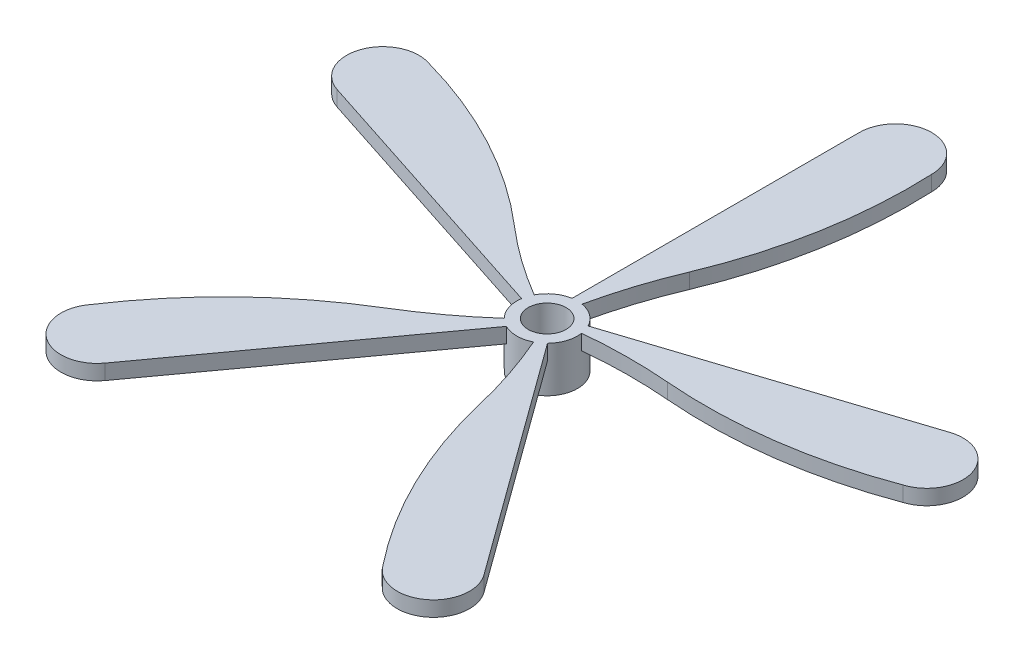
from build123d import *

# Parameters (mm, degrees)
SKETCH1_R           = 4
SKETCH1_R_2         = 2.5
BOSS_EXTRUDE1_DEPTH = 6
BOSS_EXTRUDE2_START = -2
BOSS_EXTRUDE2_DEPTH = 2
CIRPATTERN1_COUNT   = 5


with BuildPart() as part:
    # Sketch1 → Boss-Extrude1 (new body)
    with BuildSketch(Plane(origin=(0, 0, 0), x_dir=(1, 0, 0), z_dir=(0, 1, 0))):
        Circle(SKETCH1_R)
        Circle(SKETCH1_R_2, mode=Mode.SUBTRACT)
    extrude(amount=BOSS_EXTRUDE1_DEPTH)

    # Sketch2 → Boss-Extrude2 (add)
    with BuildSketch(Plane(origin=(0, 6, 0), x_dir=(1, 0, 0), z_dir=(0, 1, 0)).offset(BOSS_EXTRUDE2_START)):
        with BuildLine():
            Line((-0.659397634, 3.945274992), (-0.659397634, 41.803919823))
            ThreePointArc((-0.659397634, 41.803919823), (4.137285492, 46.574729802), (8.882082768, 41.752313842))
            ThreePointArc((8.882082768, 41.752313842), (7.966424676, 27.945777977), (4.058060811, 14.672362658))
            ThreePointArc((4.058060811, 14.672362658), (2.118281369, 9.384999918), (0.659397634, 3.945274992))
            ThreePointArc((0.659397634, 3.945274992), (0, 4), (-0.659397634, 3.945274992))
        make_face()
    boss_extrude2 = extrude(amount=BOSS_EXTRUDE2_DEPTH)

    # CirPattern1: Boss-Extrude2 ×5 about axis
    cirpattern1_axis = Axis((0, -0.3, 0), (0, 1, 0))
    for i in range(1, CIRPATTERN1_COUNT):
        add(boss_extrude2.rotate(cirpattern1_axis, i * 360 / CIRPATTERN1_COUNT))


solid = part.part
